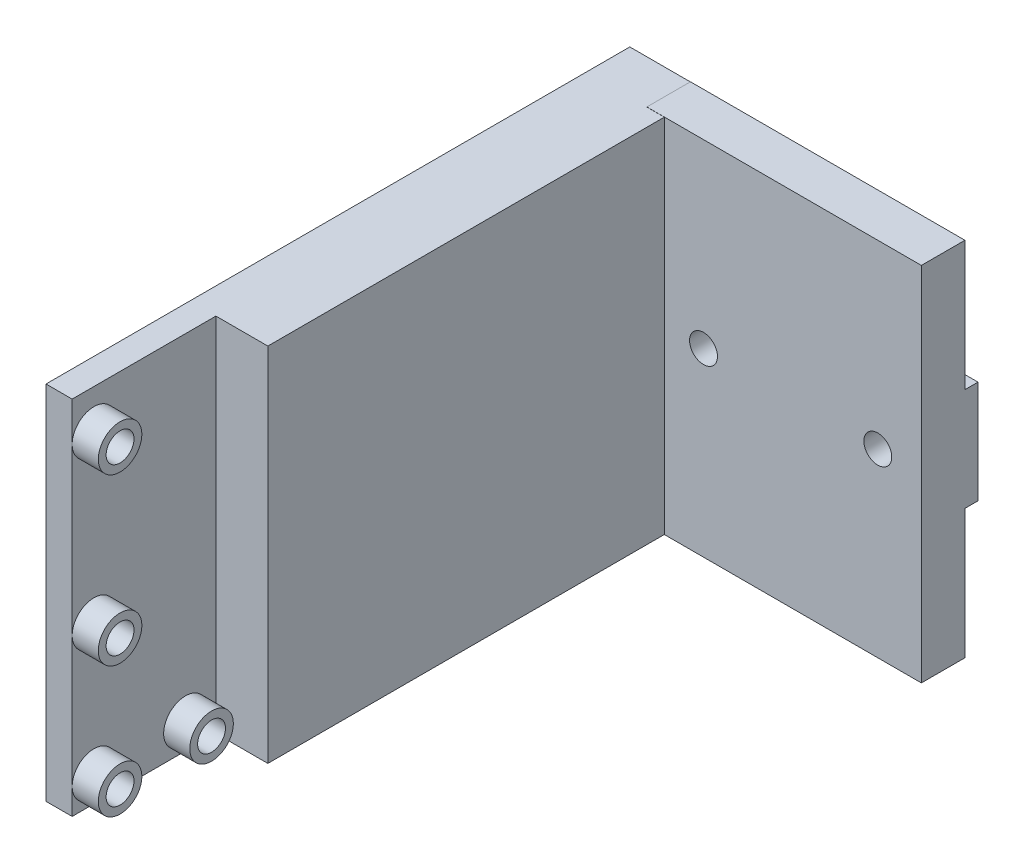
from build123d import *

# Parameters (mm, degrees)
SKETCH1_W               = 31.5
SKETCH1_H               = 41.5
BOSS_EXTRUDE1_DEPTH     = 5
SKETCH3_W               = 6
SKETCH3_H               = 41.48411863
BOSS_EXTRUDE3_DEPTH     = 50.5
SKETCH5_W               = 3
SKETCH5_H               = 41.48411863
BOSS_EXTRUDE4_DEPTH     = 16.5
SKETCH6_W               = 50.5
SKETCH6_H               = 41.48411863
BOSS_EXTRUDE6_DEPTH     = 2
SKETCH4_R               = 2.5
SKETCH4_R_2             = 1.6
BOSS_EXTRUDE7_DEPTH     = 3
SKETCH4_6_R             = 1.6
CUT_EXTRUDE1_DEPTH      = 4
CUT_EXTRUDE1_DEPTH_BACK = 36.459931403
SKETCH7_W               = 1.5
SKETCH7_H               = 11.8
BOSS_EXTRUDE8_DEPTH     = 37.5
SKETCH8_R               = 1.6
CUT_EXTRUDE2_DEPTH      = 7.5
BOSS_EXTRUDE9_DEPTH     = 0.959931


with BuildPart() as part:
    # Sketch1 → Boss-Extrude1 (new body)
    with BuildSketch(Plane.XY):
        with Locations((-107.290068597, -86.48411863)):
            Rectangle(SKETCH1_W, SKETCH1_H)
    extrude(amount=BOSS_EXTRUDE1_DEPTH)

    # Sketch3 → Boss-Extrude3 (add)
    with BuildSketch(Plane.XY):
        with Locations((-126.040068597, -86.492059315)):
            Rectangle(SKETCH3_W, SKETCH3_H)
    extrude(amount=BOSS_EXTRUDE3_DEPTH)

    # Sketch5 → Boss-Extrude4 (add)
    with BuildSketch(Plane.XY.offset(50.5)):
        with Locations((-128.5, -86.492059315)):
            Rectangle(SKETCH5_W, SKETCH5_H)
    extrude(amount=BOSS_EXTRUDE4_DEPTH)

    # Sketch6 → Boss-Extrude6 (add)
    with BuildSketch(Plane(origin=(-123.040068597, 0, 0), x_dir=(0, 0, -1), z_dir=(1, 0, 0))):
        with Locations((-25.25, -86.492059315)):
            Rectangle(SKETCH6_W, SKETCH6_H)
    extrude(amount=BOSS_EXTRUDE6_DEPTH)

    # Sketch4 → Boss-Extrude7 (add)
    with BuildSketch(Plane.ZY.offset(127)):
        with Locations((54, -104.25)):
            Circle(SKETCH4_R)
        with Locations((54, -104.25)):
            Circle(SKETCH4_R_2, mode=Mode.SUBTRACT)
        with Locations((64.5, -104.25)):
            Circle(SKETCH4_R)
        with Locations((64.5, -104.25)):
            Circle(SKETCH4_R_2, mode=Mode.SUBTRACT)
        with Locations((64.5, -89.25)):
            Circle(SKETCH4_R)
        with Locations((64.5, -89.25)):
            Circle(SKETCH4_R_2, mode=Mode.SUBTRACT)
        with Locations((64.5, -70.25)):
            Circle(SKETCH4_R)
        with Locations((64.5, -70.25)):
            Circle(SKETCH4_R_2, mode=Mode.SUBTRACT)
    extrude(amount=-BOSS_EXTRUDE7_DEPTH)

    # Sketch4_6 → Cut-Extrude1 (cut, two sides)
    with BuildSketch(Plane.ZY.offset(127)) as cut_extrude1_sk:
        with Locations((64.5, -104.25)):
            Circle(SKETCH4_6_R)
        with Locations((64.5, -89.25)):
            Circle(SKETCH4_6_R)
        with Locations((64.5, -70.25)):
            Circle(SKETCH4_6_R)
        with Locations((54, -104.25)):
            Circle(SKETCH4_6_R)
    extrude(amount=CUT_EXTRUDE1_DEPTH, mode=Mode.SUBTRACT)
    extrude(cut_extrude1_sk.sketch, amount=-CUT_EXTRUDE1_DEPTH_BACK, mode=Mode.SUBTRACT)

    # Sketch7 → Boss-Extrude8 (add)
    with BuildSketch(Plane(origin=(-91.540068597, 0, 0), x_dir=(0, 0, -1), z_dir=(1, 0, 0))):
        with Locations((0.75, -86.48411863)):
            Rectangle(SKETCH7_W, SKETCH7_H)
    extrude(amount=-BOSS_EXTRUDE8_DEPTH)

    # Sketch8 → Cut-Extrude2 (cut, through all)
    with BuildSketch(Plane.XY.offset(5)):
        with Locations((-116.540068597, -86.490848024)):
            Circle(SKETCH8_R)
        with Locations((-96.540068597, -86.485464509)):
            Circle(SKETCH8_R)
    extrude(amount=-CUT_EXTRUDE2_DEPTH, mode=Mode.SUBTRACT)

    # Sketch9 → Boss-Extrude9 (add)
    with BuildSketch(Plane.ZY.offset(129.040068597)):
        Polygon((50.5, -65.75), (0, -65.75), (0, -80.58411863), (-1.5, -80.58411863), (-1.5, -92.38411863), (0, -92.38411863), (0, -107.23411863), (50.5, -107.23411863), align=None)
    extrude(amount=BOSS_EXTRUDE9_DEPTH)


solid = part.part
